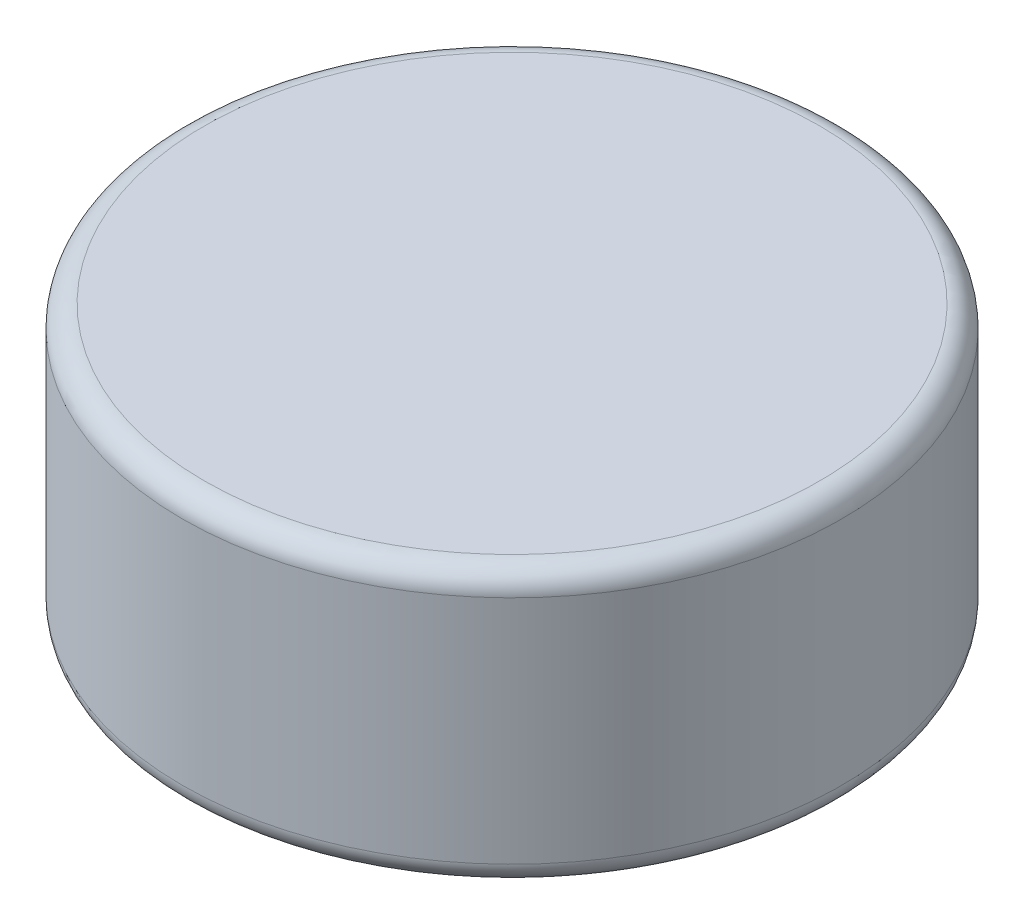
from build123d import *

# Parameters (mm, degrees)
SKETCH_1_R      = 3
EXTRUDE_1_DEPTH = 2.5
FILLET_1_R      = 0.2


with BuildPart() as part:
    # 草图1 → 凸台-拉伸1 (new body)
    with BuildSketch(Plane(origin=(0, 0, 0), x_dir=(1, 0, 0), z_dir=(0, 1, 0))):
        Circle(SKETCH_1_R)
    extrude(amount=EXTRUDE_1_DEPTH)

    # 圆角1
    fillet_1_edges = [part.edges().sort_by_distance(p)[0] for p in [
        (-3, 0, 0),
        (-3, 2.5, 0),
    ]]
    fillet(fillet_1_edges, radius=FILLET_1_R)


solid = part.part
